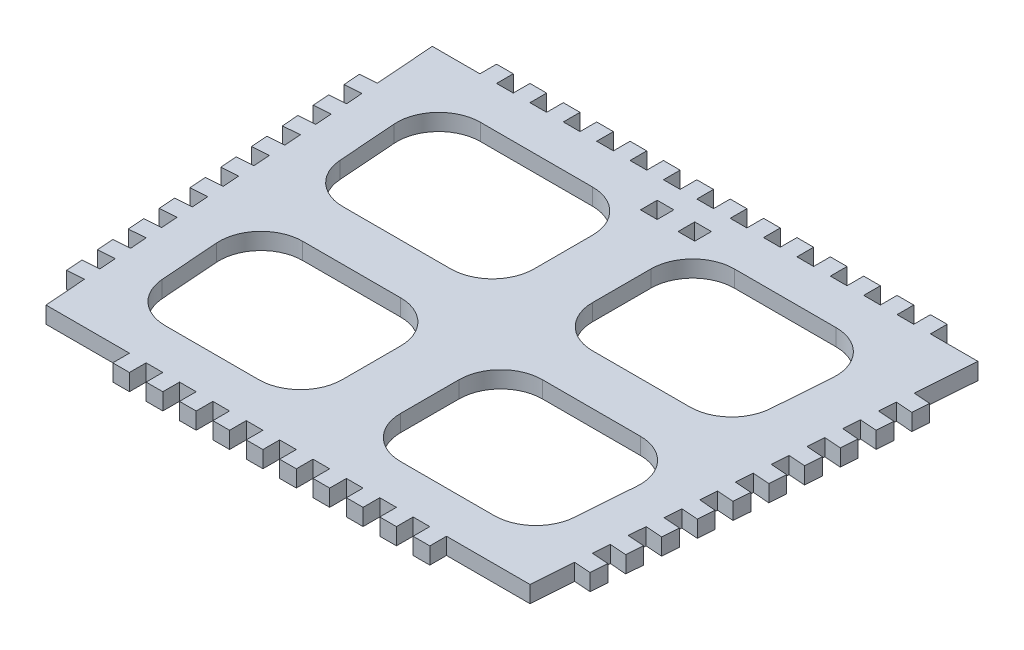
from build123d import *

# Parameters (mm, degrees)
BOSS_EXTRUDE1_DEPTH = 4
SKETCH2_W           = 4
SKETCH2_H           = 4
BOSS_EXTRUDE2_DEPTH = 4
SKETCH4_W           = 4
SKETCH4_H           = 4
CUT_EXTRUDE1_DEPTH  = 10
BOSS_EXTRUDE3_DEPTH = 4


with BuildPart() as part:
    # Sketch1 → Boss-Extrude1 (new body)
    with BuildSketch(Plane(origin=(0, 0, 0), x_dir=(1, 0, 0), z_dir=(0, 1, 0))):
        Polygon((-65.4, 43.024336283), (0, 43.024336283), (65.4, 43.024336283), (58, -56.975663717), (0, -56.975663717), (-58, -56.975663717), align=None)
    extrude(amount=BOSS_EXTRUDE1_DEPTH)

    # Sketch2 → Boss-Extrude2 (add)
    with BuildSketch(Plane(origin=(0, 4, 0), x_dir=(1, 0, 0), z_dir=(0, 1, 0))):
        with Locations((-4, 45.024336283)):
            Rectangle(SKETCH2_W, SKETCH2_H)
        with Locations((-12, 45.024336283)):
            Rectangle(SKETCH2_W, SKETCH2_H)
        with Locations((-20, 45.024336283)):
            Rectangle(SKETCH2_W, SKETCH2_H)
        with Locations((-28, 45.024336283)):
            Rectangle(SKETCH2_W, SKETCH2_H)
        with Locations((-36, 45.024336283)):
            Rectangle(SKETCH2_W, SKETCH2_H)
        with Locations((-44, 45.024336283)):
            Rectangle(SKETCH2_W, SKETCH2_H)
        with Locations((-52, 45.024336283)):
            Rectangle(SKETCH2_W, SKETCH2_H)
        with Locations((52, 45.024336283)):
            Rectangle(SKETCH2_W, SKETCH2_H)
        with Locations((44, 45.024336283)):
            Rectangle(SKETCH2_W, SKETCH2_H)
        with Locations((36, 45.024336283)):
            Rectangle(SKETCH2_W, SKETCH2_H)
        with Locations((28, 45.024336283)):
            Rectangle(SKETCH2_W, SKETCH2_H)
        with Locations((20, 45.024336283)):
            Rectangle(SKETCH2_W, SKETCH2_H)
        with Locations((12, 45.024336283)):
            Rectangle(SKETCH2_W, SKETCH2_H)
        with Locations((4, 45.024336283)):
            Rectangle(SKETCH2_W, SKETCH2_H)
        with Locations((-4, -58.975663717)):
            Rectangle(SKETCH2_W, SKETCH2_H)
        with Locations((-12, -58.975663717)):
            Rectangle(SKETCH2_W, SKETCH2_H)
        with Locations((-20, -58.975663717)):
            Rectangle(SKETCH2_W, SKETCH2_H)
        with Locations((-28, -58.975663717)):
            Rectangle(SKETCH2_W, SKETCH2_H)
        with Locations((-36, -58.975663717)):
            Rectangle(SKETCH2_W, SKETCH2_H)
        with Locations((36, -58.975663717)):
            Rectangle(SKETCH2_W, SKETCH2_H)
        with Locations((28, -58.975663717)):
            Rectangle(SKETCH2_W, SKETCH2_H)
        with Locations((20, -58.975663717)):
            Rectangle(SKETCH2_W, SKETCH2_H)
        with Locations((12, -58.975663717)):
            Rectangle(SKETCH2_W, SKETCH2_H)
        with Locations((4, -58.975663717)):
            Rectangle(SKETCH2_W, SKETCH2_H)
    extrude(amount=-BOSS_EXTRUDE2_DEPTH)

    # Sketch4 → Cut-Extrude1 (cut)
    with BuildSketch(Plane(origin=(0, 4, 0), x_dir=(1, 0, 0), z_dir=(0, 1, 0))):
        with BuildLine():
            Line((-53.838046701, 22.28635412), (-52.802046701, 8.28635412))
            ThreePointArc((-52.802046701, 8.28635412), (-49.634466427, 1.696996328), (-42.829314762, -0.975663717))
            Line((-42.829314762, -0.975663717), (-17, -0.975663717))
            ThreePointArc((-17, -0.975663717), (-9.928932188, 1.953268471), (-7, 9.024336283))
            Line((-7, 9.024336283), (-7, 23.024336283))
            ThreePointArc((-7, 23.024336283), (-9.928932188, 30.095404095), (-17, 33.024336283))
            Line((-17, 33.024336283), (-43.865314762, 33.024336283))
            ThreePointArc((-43.865314762, 33.024336283), (-51.192654717, 29.829487948), (-53.838046701, 22.28635412))
        make_face()
        with BuildLine():
            Line((7, 23.024336283), (7, 9.024336283))
            ThreePointArc((7, 9.024336283), (9.928932188, 1.953268471), (17, -0.975663717))
            Line((17, -0.975663717), (40.357644215, -0.975663717))
            ThreePointArc((40.357644215, -0.975663717), (47.16279588, 1.696996328), (50.330376154, 8.28635412))
            Line((50.330376154, 8.28635412), (51.366376154, 22.28635412))
            ThreePointArc((51.366376154, 22.28635412), (48.72098417, 29.829487948), (41.393644215, 33.024336283))
            Line((41.393644215, 33.024336283), (17, 33.024336283))
            ThreePointArc((17, 33.024336283), (9.928932188, 30.095404095), (7, 23.024336283))
        make_face()
        with Locations((-4.5, 36.024336283)):
            Rectangle(SKETCH4_W, SKETCH4_H)
        with BuildLine():
            Line((-50.434046701, -23.71364588), (-49.398046701, -37.71364588))
            ThreePointArc((-49.398046701, -37.71364588), (-46.230466427, -44.303003672), (-39.425314762, -46.975663717))
            Line((-39.425314762, -46.975663717), (-17, -46.975663717))
            ThreePointArc((-17, -46.975663717), (-9.928932188, -44.046731529), (-7, -36.975663717))
            Line((-7, -36.975663717), (-7, -22.975663717))
            ThreePointArc((-7, -22.975663717), (-9.928932188, -15.904595905), (-17, -12.975663717))
            Line((-17, -12.975663717), (-40.461314762, -12.975663717))
            ThreePointArc((-40.461314762, -12.975663717), (-47.788654717, -16.170512052), (-50.434046701, -23.71364588))
        make_face()
        with BuildLine():
            Line((7, -22.975663717), (7, -36.975663717))
            ThreePointArc((7, -36.975663717), (9.928932188, -44.046731529), (17, -46.975663717))
            Line((17, -46.975663717), (39.425314762, -46.975663717))
            ThreePointArc((39.425314762, -46.975663717), (46.230466427, -44.303003672), (49.398046701, -37.71364588))
            Line((49.398046701, -37.71364588), (50.434046701, -23.71364588))
            ThreePointArc((50.434046701, -23.71364588), (47.788654717, -16.170512052), (40.461314762, -12.975663717))
            Line((40.461314762, -12.975663717), (17, -12.975663717))
            ThreePointArc((17, -12.975663717), (9.928932188, -15.904595905), (7, -22.975663717))
        make_face()
        with Locations((4.5, 36.024336283)):
            Rectangle(SKETCH4_W, SKETCH4_H)
    extrude(amount=-CUT_EXTRUDE1_DEPTH, mode=Mode.SUBTRACT)

    # Sketch5 → Boss-Extrude3 (add)
    with BuildSketch(Plane(origin=(0, 4, 0), x_dir=(1, 0, 0), z_dir=(0, 1, 0))):
        Polygon((-59.62356076, -35.035653451), (-63.612653535, -35.330846316), (-63.31746067, -39.319939092), (-59.328367894, -39.024746227), align=None)
        Polygon((-59.033175029, -43.013839002), (-63.022267804, -43.309031868), (-62.727074939, -47.298124643), (-58.737982163, -47.002931778), align=None)
        Polygon((-60.21394649, -27.0574679), (-64.203039266, -27.352660765), (-63.907846401, -31.341753541), (-59.918753625, -31.046560676), align=None)
        Polygon((-60.804332221, -19.079282349), (-64.793424997, -19.374475214), (-64.498232131, -23.36356799), (-60.509139356, -23.068375124), align=None)
        Polygon((-61.394717952, -11.101096798), (-65.383810728, -11.396289663), (-65.088617862, -15.385382439), (-61.099525087, -15.090189573), align=None)
        Polygon((-61.985103683, -3.122911246), (-65.974196458, -3.418104112), (-65.679003593, -7.407196887), (-61.689910817, -7.112004022), align=None)
        Polygon((-62.575489414, 4.855274305), (-66.564582189, 4.560081439), (-66.269389324, 0.570988664), (-62.280296548, 0.866181529), align=None)
        Polygon((-63.165875144, 12.833459856), (-67.15496792, 12.538266991), (-66.859775055, 8.549174215), (-62.870682279, 8.84436708), align=None)
        Polygon((-63.756260875, 20.811645407), (-67.745353651, 20.516452542), (-67.450160785, 16.527359766), (-63.46106801, 16.822552632), align=None)
        Polygon((-64.346646606, 28.789830958), (-68.335739382, 28.494638093), (-68.040546516, 24.505545317), (-64.051453741, 24.800738183), align=None)
        Polygon((64.051453741, 24.800738183), (64.346646606, 28.789830958), (68.335739382, 28.494638093), (68.040546516, 24.505545317), align=None)
        Polygon((63.46106801, 16.822552632), (63.756260875, 20.811645407), (67.745353651, 20.516452542), (67.450160785, 16.527359766), align=None)
        Polygon((62.870682279, 8.84436708), (63.165875144, 12.833459856), (67.15496792, 12.538266991), (66.859775055, 8.549174215), align=None)
        Polygon((62.280296548, 0.866181529), (62.575489414, 4.855274305), (66.564582189, 4.560081439), (66.269389324, 0.570988664), align=None)
        Polygon((61.689910817, -7.112004022), (61.985103683, -3.122911246), (65.974196458, -3.418104112), (65.679003593, -7.407196887), align=None)
        Polygon((61.099525087, -15.090189573), (61.394717952, -11.101096798), (65.383810728, -11.396289663), (65.088617862, -15.385382439), align=None)
        Polygon((60.509139356, -23.068375124), (60.804332221, -19.079282349), (64.793424997, -19.374475214), (64.498232131, -23.36356799), align=None)
        Polygon((59.918753625, -31.046560676), (60.21394649, -27.0574679), (64.203039266, -27.352660765), (63.907846401, -31.341753541), align=None)
        Polygon((58.737982163, -47.002931778), (59.033175029, -43.013839002), (63.022267804, -43.309031868), (62.727074939, -47.298124643), align=None)
        Polygon((59.328367894, -39.024746227), (59.62356076, -35.035653451), (63.612653535, -35.330846316), (63.31746067, -39.319939092), align=None)
    extrude(amount=-BOSS_EXTRUDE3_DEPTH)


solid = part.part
